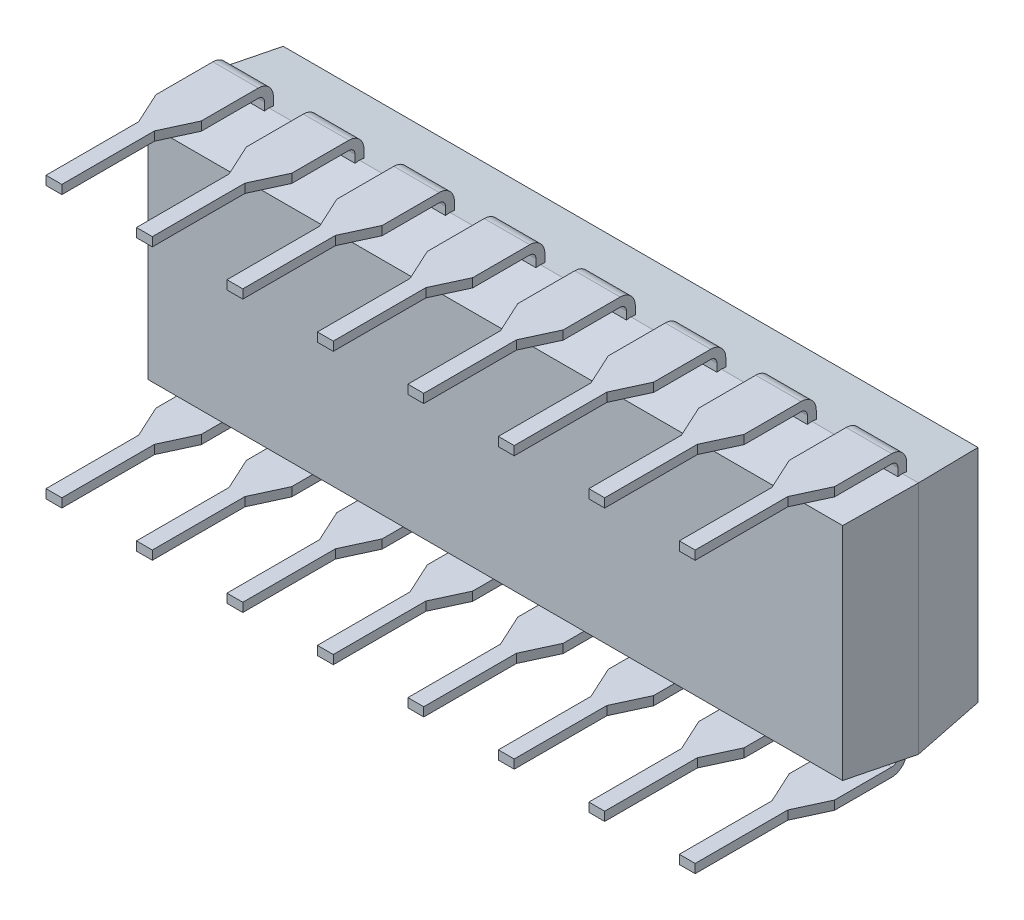
from build123d import *

# Parameters (mm, degrees)
RESSALTO_EXTRUS_O1_DEPTH        = 9.98
CORTE_EXTRUS_O2_DEPTH           = 3.55
ESBO_O8_R                       = 1
CORTE_EXTRUS_O5_DEPTH           = 0.5
ESBO_O6_W                       = 1.275
ESBO_O6_H                       = 0.25
RESSALTO_EXTRUS_O2_DEPTH        = 0.025
ESBO_O7_W                       = 1.275
ESBO_O7_H                       = 0.25
CORTE_EXTRUS_O6_DEPTH           = 0.25
ESBO_O10_W                      = 0.445
ESBO_O10_H                      = 0.25
RESSALTO_EXTRUS_O3_DEPTH        = 2.6
PADR_O_LINEAR1_COUNT            = 8
PADR_O_LINEAR1_PITCH            = 2.54
PADR_O_LINEAR1_COPY_1_SKETCH_W  = 1.275
PADR_O_LINEAR1_COPY_1_SKETCH_H  = 0.25
PADR_O_LINEAR1_COPY_1_DEPTH     = 0.025
PADR_O_LINEAR1_COPY_2_SKETCH_W  = 1.275
PADR_O_LINEAR1_COPY_2_SKETCH_H  = 0.25
PADR_O_LINEAR1_COPY_2_DEPTH     = 0.025
PADR_O_LINEAR1_COPY_3_SKETCH_W  = 1.275
PADR_O_LINEAR1_COPY_3_SKETCH_H  = 0.25
PADR_O_LINEAR1_COPY_3_DEPTH     = 0.025
PADR_O_LINEAR1_COPY_4_SKETCH_W  = 1.275
PADR_O_LINEAR1_COPY_4_SKETCH_H  = 0.25
PADR_O_LINEAR1_COPY_4_DEPTH     = 0.025
PADR_O_LINEAR1_COPY_5_SKETCH_W  = 1.275
PADR_O_LINEAR1_COPY_5_SKETCH_H  = 0.25
PADR_O_LINEAR1_COPY_5_DEPTH     = 0.025
PADR_O_LINEAR1_COPY_6_SKETCH_W  = 1.275
PADR_O_LINEAR1_COPY_6_SKETCH_H  = 0.25
PADR_O_LINEAR1_COPY_6_DEPTH     = 0.025
PADR_O_LINEAR1_COPY_7_SKETCH_W  = 1.275
PADR_O_LINEAR1_COPY_7_SKETCH_H  = 0.25
PADR_O_LINEAR1_COPY_7_DEPTH     = 0.025
PADR_O_LINEAR1_COPY_8_SKETCH_W  = 1.275
PADR_O_LINEAR1_COPY_8_SKETCH_H  = 0.25
PADR_O_LINEAR1_COPY_9_SKETCH_W  = 1.275
PADR_O_LINEAR1_COPY_9_SKETCH_H  = 0.25
PADR_O_LINEAR1_COPY_10_SKETCH_W = 1.275
PADR_O_LINEAR1_COPY_10_SKETCH_H = 0.25
PADR_O_LINEAR1_COPY_11_SKETCH_W = 1.275
PADR_O_LINEAR1_COPY_11_SKETCH_H = 0.25
PADR_O_LINEAR1_COPY_12_SKETCH_W = 1.275
PADR_O_LINEAR1_COPY_12_SKETCH_H = 0.25
PADR_O_LINEAR1_COPY_13_SKETCH_W = 1.275
PADR_O_LINEAR1_COPY_13_SKETCH_H = 0.25
PADR_O_LINEAR1_COPY_14_SKETCH_W = 1.275
PADR_O_LINEAR1_COPY_14_SKETCH_H = 0.25
PADR_O_LINEAR1_COPY_15_DEPTH    = 0.25
PADR_O_LINEAR1_COPY_16_DEPTH    = 0.25
PADR_O_LINEAR1_COPY_17_DEPTH    = 0.25
PADR_O_LINEAR1_COPY_18_DEPTH    = 0.25
PADR_O_LINEAR1_COPY_19_DEPTH    = 0.25
PADR_O_LINEAR1_COPY_20_DEPTH    = 0.25
PADR_O_LINEAR1_COPY_21_DEPTH    = 0.25
PADR_O_LINEAR1_COPY_22_SKETCH_W = 0.445
PADR_O_LINEAR1_COPY_22_SKETCH_H = 0.25
PADR_O_LINEAR1_COPY_22_DEPTH    = 2.6
PADR_O_LINEAR1_COPY_23_SKETCH_W = 0.445
PADR_O_LINEAR1_COPY_23_SKETCH_H = 0.25
PADR_O_LINEAR1_COPY_23_DEPTH    = 2.6
PADR_O_LINEAR1_COPY_24_SKETCH_W = 0.445
PADR_O_LINEAR1_COPY_24_SKETCH_H = 0.25
PADR_O_LINEAR1_COPY_24_DEPTH    = 2.6
PADR_O_LINEAR1_COPY_25_SKETCH_W = 0.445
PADR_O_LINEAR1_COPY_25_SKETCH_H = 0.25
PADR_O_LINEAR1_COPY_25_DEPTH    = 2.6
PADR_O_LINEAR1_COPY_26_SKETCH_W = 0.445
PADR_O_LINEAR1_COPY_26_SKETCH_H = 0.25
PADR_O_LINEAR1_COPY_26_DEPTH    = 2.6
PADR_O_LINEAR1_COPY_27_SKETCH_W = 0.445
PADR_O_LINEAR1_COPY_27_SKETCH_H = 0.25
PADR_O_LINEAR1_COPY_27_DEPTH    = 2.6
PADR_O_LINEAR1_COPY_28_SKETCH_W = 0.445
PADR_O_LINEAR1_COPY_28_SKETCH_H = 0.25
PADR_O_LINEAR1_COPY_28_DEPTH    = 2.6


with BuildPart() as part:
    # Esboço1 → Ressalto-extrusão1 (new body, symmetric)
    with BuildSketch(Plane(origin=(0, 0, 0), x_dir=(0, 0, -1), z_dir=(1, 0, 0))):
        Polygon((0.9, 3.1), (0.9, -3.1), (2.8, -3.3), (4.7, -3.1), (4.7, 3.1), (2.8, 3.3), align=None)
    extrude(amount=RESSALTO_EXTRUS_O1_DEPTH, both=True)

    # Esboço3 → Corte-extrusão2 (cut, symmetric)
    with BuildSketch(Plane(origin=(0, 0, 0), x_dir=(1, 0, 0), z_dir=(0, 1, 0))):
        Polygon((-9.98, 2.8), (-9.749897634, 4.726835982), (-10.916348907, 4.726835982), (-10.916348907, 0.873164018), (-9.749897634, 0.873164018), align=None)
    corte_extrus_o2 = extrude(amount=CORTE_EXTRUS_O2_DEPTH, both=True, mode=Mode.SUBTRACT)

    # Espelhar1: Corte-extrusão2 across plane
    add(corte_extrus_o2.mirror(Plane(origin=(0, 0, 0), x_dir=(0, 0, 1), z_dir=(1, 0, 0))), mode=Mode.SUBTRACT)

    # Esboço8 → Corte-extrusão5 (cut)
    with BuildSketch(Plane(origin=(0, 0, -4.7), x_dir=(-1, 0, 0), z_dir=(0, 0, -1))):
        with Locations((9.753102382, 0)):
            Circle(ESBO_O8_R)
    extrude(amount=-CORTE_EXTRUS_O5_DEPTH, mode=Mode.SUBTRACT)

    # Esboço6 → Ressalto-extrusão2 (add, symmetric)
    with BuildSketch(Plane(origin=(0, 3.3, 0), x_dir=(1, 0, 0), z_dir=(0, 1, 0))):
        with Locations((-8.89, 2.8)):
            Rectangle(ESBO_O6_W, ESBO_O6_H)
    ressalto_extrus_o2 = extrude(amount=RESSALTO_EXTRUS_O2_DEPTH, both=True)

    # Varredura1: sweep along a curve in space
    with BuildLine() as varredura1_path:
        Line((-8.89, 3.325, -2.8), (-8.89, 3.51, -2.8))
        ThreePointArc((-8.89, 3.51, -2.8), (-8.89, 3.722132034, -2.712132034), (-8.89, 3.81, -2.5))
        Line((-8.89, 3.81, -2.5), (-8.89, 3.81, 0))
    # Esboço7 → Varredura1 (sweep)
    with BuildSketch(Plane(origin=(0, 3.325, 0), x_dir=(1, 0, 0), z_dir=(0, 1, 0))):
        with Locations((-8.89, 2.8)):
            Rectangle(ESBO_O7_W, ESBO_O7_H)
    varredura1 = sweep(path=varredura1_path.line)

    # Esboço9 → Corte-extrusão6 (cut)
    with BuildSketch(Plane(origin=(0, 3.935, 0), x_dir=(1, 0, 0), z_dir=(0, 1, 0))):
        Polygon((-9.1125, 0), (-9.5275, 0.9), (-9.5275, -0.2), (-8.2525, -0.2), (-8.2525, 0.9), (-8.6675, 0), align=None)
    corte_extrus_o6 = extrude(amount=-CORTE_EXTRUS_O6_DEPTH, mode=Mode.SUBTRACT)

    # Esboço10 → Ressalto-extrusão3 (add)
    with BuildSketch(Plane.XY):
        with Locations((-8.89, 3.81)):
            Rectangle(ESBO_O10_W, ESBO_O10_H)
    ressalto_extrus_o3 = extrude(amount=RESSALTO_EXTRUS_O3_DEPTH)

    # Espelhar2: Ressalto-extrusão2, Varredura1, Corte-extrusão6, Ressalto-extrusão3 across plane
    add(ressalto_extrus_o2.mirror(Plane.ZX))
    add(varredura1.mirror(Plane.ZX))
    add(corte_extrus_o6.mirror(Plane.ZX), mode=Mode.SUBTRACT)
    add(ressalto_extrus_o3.mirror(Plane.ZX))

    # Padrão linear1: Ressalto-extrusão2, Varredura1, Corte-extrusão6, Ressalto-extrusão3 ×8
    with Locations(*[(i * PADR_O_LINEAR1_PITCH, 0, 0) for i in range(1, PADR_O_LINEAR1_COUNT)]):
        add(ressalto_extrus_o2)
        add(varredura1)
        add(corte_extrus_o6, mode=Mode.SUBTRACT)
        add(ressalto_extrus_o3)

    # Padrão linear1 copy 1 sketch → Padrão linear1 copy 1 (add, symmetric)
    with BuildSketch(Plane(origin=(2.54, -3.3, 0), x_dir=(1, 0, 0), z_dir=(0, -1, 0))):
        with Locations((-8.89, -2.8)):
            Rectangle(PADR_O_LINEAR1_COPY_1_SKETCH_W, PADR_O_LINEAR1_COPY_1_SKETCH_H)
    extrude(amount=PADR_O_LINEAR1_COPY_1_DEPTH, both=True)

    # Padrão linear1 copy 2 sketch → Padrão linear1 copy 2 (add, symmetric)
    with BuildSketch(Plane(origin=(5.08, -3.3, 0), x_dir=(1, 0, 0), z_dir=(0, -1, 0))):
        with Locations((-8.89, -2.8)):
            Rectangle(PADR_O_LINEAR1_COPY_2_SKETCH_W, PADR_O_LINEAR1_COPY_2_SKETCH_H)
    extrude(amount=PADR_O_LINEAR1_COPY_2_DEPTH, both=True)

    # Padrão linear1 copy 3 sketch → Padrão linear1 copy 3 (add, symmetric)
    with BuildSketch(Plane(origin=(7.62, -3.3, 0), x_dir=(1, 0, 0), z_dir=(0, -1, 0))):
        with Locations((-8.89, -2.8)):
            Rectangle(PADR_O_LINEAR1_COPY_3_SKETCH_W, PADR_O_LINEAR1_COPY_3_SKETCH_H)
    extrude(amount=PADR_O_LINEAR1_COPY_3_DEPTH, both=True)

    # Padrão linear1 copy 4 sketch → Padrão linear1 copy 4 (add, symmetric)
    with BuildSketch(Plane(origin=(10.16, -3.3, 0), x_dir=(1, 0, 0), z_dir=(0, -1, 0))):
        with Locations((-8.89, -2.8)):
            Rectangle(PADR_O_LINEAR1_COPY_4_SKETCH_W, PADR_O_LINEAR1_COPY_4_SKETCH_H)
    extrude(amount=PADR_O_LINEAR1_COPY_4_DEPTH, both=True)

    # Padrão linear1 copy 5 sketch → Padrão linear1 copy 5 (add, symmetric)
    with BuildSketch(Plane(origin=(12.7, -3.3, 0), x_dir=(1, 0, 0), z_dir=(0, -1, 0))):
        with Locations((-8.89, -2.8)):
            Rectangle(PADR_O_LINEAR1_COPY_5_SKETCH_W, PADR_O_LINEAR1_COPY_5_SKETCH_H)
    extrude(amount=PADR_O_LINEAR1_COPY_5_DEPTH, both=True)

    # Padrão linear1 copy 6 sketch → Padrão linear1 copy 6 (add, symmetric)
    with BuildSketch(Plane(origin=(15.24, -3.3, 0), x_dir=(1, 0, 0), z_dir=(0, -1, 0))):
        with Locations((-8.89, -2.8)):
            Rectangle(PADR_O_LINEAR1_COPY_6_SKETCH_W, PADR_O_LINEAR1_COPY_6_SKETCH_H)
    extrude(amount=PADR_O_LINEAR1_COPY_6_DEPTH, both=True)

    # Padrão linear1 copy 7 sketch → Padrão linear1 copy 7 (add, symmetric)
    with BuildSketch(Plane(origin=(17.78, -3.3, 0), x_dir=(1, 0, 0), z_dir=(0, -1, 0))):
        with Locations((-8.89, -2.8)):
            Rectangle(PADR_O_LINEAR1_COPY_7_SKETCH_W, PADR_O_LINEAR1_COPY_7_SKETCH_H)
    extrude(amount=PADR_O_LINEAR1_COPY_7_DEPTH, both=True)

    # Padrão linear1 copy 8: sweep along a curve in space
    with BuildLine() as padr_o_linear1_copy_8_path:
        Line((-6.35, -3.325, -2.8), (-6.35, -3.51, -2.8))
        ThreePointArc((-6.35, -3.51, -2.8), (-6.35, -3.722132034, -2.712132034), (-6.35, -3.81, -2.5))
        Line((-6.35, -3.81, -2.5), (-6.35, -3.81, 0))
    # Padrão linear1 copy 8 sketch → Padrão linear1 copy 8 (sweep)
    with BuildSketch(Plane(origin=(2.54, -3.325, 0), x_dir=(1, 0, 0), z_dir=(0, -1, 0))):
        with Locations((-8.89, -2.8)):
            Rectangle(PADR_O_LINEAR1_COPY_8_SKETCH_W, PADR_O_LINEAR1_COPY_8_SKETCH_H)
    sweep(path=padr_o_linear1_copy_8_path.line)

    # Padrão linear1 copy 9: sweep along a curve in space
    with BuildLine() as padr_o_linear1_copy_9_path:
        Line((-3.81, -3.325, -2.8), (-3.81, -3.51, -2.8))
        ThreePointArc((-3.81, -3.51, -2.8), (-3.81, -3.722132034, -2.712132034), (-3.81, -3.81, -2.5))
        Line((-3.81, -3.81, -2.5), (-3.81, -3.81, 0))
    # Padrão linear1 copy 9 sketch → Padrão linear1 copy 9 (sweep)
    with BuildSketch(Plane(origin=(5.08, -3.325, 0), x_dir=(1, 0, 0), z_dir=(0, -1, 0))):
        with Locations((-8.89, -2.8)):
            Rectangle(PADR_O_LINEAR1_COPY_9_SKETCH_W, PADR_O_LINEAR1_COPY_9_SKETCH_H)
    sweep(path=padr_o_linear1_copy_9_path.line)

    # Padrão linear1 copy 10: sweep along a curve in space
    with BuildLine() as padr_o_linear1_copy_10_path:
        Line((-1.27, -3.325, -2.8), (-1.27, -3.51, -2.8))
        ThreePointArc((-1.27, -3.51, -2.8), (-1.27, -3.722132034, -2.712132034), (-1.27, -3.81, -2.5))
        Line((-1.27, -3.81, -2.5), (-1.27, -3.81, 0))
    # Padrão linear1 copy 10 sketch → Padrão linear1 copy 10 (sweep)
    with BuildSketch(Plane(origin=(7.62, -3.325, 0), x_dir=(1, 0, 0), z_dir=(0, -1, 0))):
        with Locations((-8.89, -2.8)):
            Rectangle(PADR_O_LINEAR1_COPY_10_SKETCH_W, PADR_O_LINEAR1_COPY_10_SKETCH_H)
    sweep(path=padr_o_linear1_copy_10_path.line)

    # Padrão linear1 copy 11: sweep along a curve in space
    with BuildLine() as padr_o_linear1_copy_11_path:
        Line((1.27, -3.325, -2.8), (1.27, -3.51, -2.8))
        ThreePointArc((1.27, -3.51, -2.8), (1.27, -3.722132034, -2.712132034), (1.27, -3.81, -2.5))
        Line((1.27, -3.81, -2.5), (1.27, -3.81, 0))
    # Padrão linear1 copy 11 sketch → Padrão linear1 copy 11 (sweep)
    with BuildSketch(Plane(origin=(10.16, -3.325, 0), x_dir=(1, 0, 0), z_dir=(0, -1, 0))):
        with Locations((-8.89, -2.8)):
            Rectangle(PADR_O_LINEAR1_COPY_11_SKETCH_W, PADR_O_LINEAR1_COPY_11_SKETCH_H)
    sweep(path=padr_o_linear1_copy_11_path.line)

    # Padrão linear1 copy 12: sweep along a curve in space
    with BuildLine() as padr_o_linear1_copy_12_path:
        Line((3.81, -3.325, -2.8), (3.81, -3.51, -2.8))
        ThreePointArc((3.81, -3.51, -2.8), (3.81, -3.722132034, -2.712132034), (3.81, -3.81, -2.5))
        Line((3.81, -3.81, -2.5), (3.81, -3.81, 0))
    # Padrão linear1 copy 12 sketch → Padrão linear1 copy 12 (sweep)
    with BuildSketch(Plane(origin=(12.7, -3.325, 0), x_dir=(1, 0, 0), z_dir=(0, -1, 0))):
        with Locations((-8.89, -2.8)):
            Rectangle(PADR_O_LINEAR1_COPY_12_SKETCH_W, PADR_O_LINEAR1_COPY_12_SKETCH_H)
    sweep(path=padr_o_linear1_copy_12_path.line)

    # Padrão linear1 copy 13: sweep along a curve in space
    with BuildLine() as padr_o_linear1_copy_13_path:
        Line((6.35, -3.325, -2.8), (6.35, -3.51, -2.8))
        ThreePointArc((6.35, -3.51, -2.8), (6.35, -3.722132034, -2.712132034), (6.35, -3.81, -2.5))
        Line((6.35, -3.81, -2.5), (6.35, -3.81, 0))
    # Padrão linear1 copy 13 sketch → Padrão linear1 copy 13 (sweep)
    with BuildSketch(Plane(origin=(15.24, -3.325, 0), x_dir=(1, 0, 0), z_dir=(0, -1, 0))):
        with Locations((-8.89, -2.8)):
            Rectangle(PADR_O_LINEAR1_COPY_13_SKETCH_W, PADR_O_LINEAR1_COPY_13_SKETCH_H)
    sweep(path=padr_o_linear1_copy_13_path.line)

    # Padrão linear1 copy 14: sweep along a curve in space
    with BuildLine() as padr_o_linear1_copy_14_path:
        Line((8.89, -3.325, -2.8), (8.89, -3.51, -2.8))
        ThreePointArc((8.89, -3.51, -2.8), (8.89, -3.722132034, -2.712132034), (8.89, -3.81, -2.5))
        Line((8.89, -3.81, -2.5), (8.89, -3.81, 0))
    # Padrão linear1 copy 14 sketch → Padrão linear1 copy 14 (sweep)
    with BuildSketch(Plane(origin=(17.78, -3.325, 0), x_dir=(1, 0, 0), z_dir=(0, -1, 0))):
        with Locations((-8.89, -2.8)):
            Rectangle(PADR_O_LINEAR1_COPY_14_SKETCH_W, PADR_O_LINEAR1_COPY_14_SKETCH_H)
    sweep(path=padr_o_linear1_copy_14_path.line)

    # Padrão linear1 copy 15 sketch → Padrão linear1 copy 15 (cut)
    with BuildSketch(Plane(origin=(2.54, -3.935, 0), x_dir=(1, 0, 0), z_dir=(0, -1, 0))):
        Polygon((-9.1125, 0), (-9.5275, -0.9), (-9.5275, 0.2), (-8.2525, 0.2), (-8.2525, -0.9), (-8.6675, 0), align=None)
    extrude(amount=-PADR_O_LINEAR1_COPY_15_DEPTH, mode=Mode.SUBTRACT)

    # Padrão linear1 copy 16 sketch → Padrão linear1 copy 16 (cut)
    with BuildSketch(Plane(origin=(5.08, -3.935, 0), x_dir=(1, 0, 0), z_dir=(0, -1, 0))):
        Polygon((-9.1125, 0), (-9.5275, -0.9), (-9.5275, 0.2), (-8.2525, 0.2), (-8.2525, -0.9), (-8.6675, 0), align=None)
    extrude(amount=-PADR_O_LINEAR1_COPY_16_DEPTH, mode=Mode.SUBTRACT)

    # Padrão linear1 copy 17 sketch → Padrão linear1 copy 17 (cut)
    with BuildSketch(Plane(origin=(7.62, -3.935, 0), x_dir=(1, 0, 0), z_dir=(0, -1, 0))):
        Polygon((-9.1125, 0), (-9.5275, -0.9), (-9.5275, 0.2), (-8.2525, 0.2), (-8.2525, -0.9), (-8.6675, 0), align=None)
    extrude(amount=-PADR_O_LINEAR1_COPY_17_DEPTH, mode=Mode.SUBTRACT)

    # Padrão linear1 copy 18 sketch → Padrão linear1 copy 18 (cut)
    with BuildSketch(Plane(origin=(10.16, -3.935, 0), x_dir=(1, 0, 0), z_dir=(0, -1, 0))):
        Polygon((-9.1125, 0), (-9.5275, -0.9), (-9.5275, 0.2), (-8.2525, 0.2), (-8.2525, -0.9), (-8.6675, 0), align=None)
    extrude(amount=-PADR_O_LINEAR1_COPY_18_DEPTH, mode=Mode.SUBTRACT)

    # Padrão linear1 copy 19 sketch → Padrão linear1 copy 19 (cut)
    with BuildSketch(Plane(origin=(12.7, -3.935, 0), x_dir=(1, 0, 0), z_dir=(0, -1, 0))):
        Polygon((-9.1125, 0), (-9.5275, -0.9), (-9.5275, 0.2), (-8.2525, 0.2), (-8.2525, -0.9), (-8.6675, 0), align=None)
    extrude(amount=-PADR_O_LINEAR1_COPY_19_DEPTH, mode=Mode.SUBTRACT)

    # Padrão linear1 copy 20 sketch → Padrão linear1 copy 20 (cut)
    with BuildSketch(Plane(origin=(15.24, -3.935, 0), x_dir=(1, 0, 0), z_dir=(0, -1, 0))):
        Polygon((-9.1125, 0), (-9.5275, -0.9), (-9.5275, 0.2), (-8.2525, 0.2), (-8.2525, -0.9), (-8.6675, 0), align=None)
    extrude(amount=-PADR_O_LINEAR1_COPY_20_DEPTH, mode=Mode.SUBTRACT)

    # Padrão linear1 copy 21 sketch → Padrão linear1 copy 21 (cut)
    with BuildSketch(Plane(origin=(17.78, -3.935, 0), x_dir=(1, 0, 0), z_dir=(0, -1, 0))):
        Polygon((-9.1125, 0), (-9.5275, -0.9), (-9.5275, 0.2), (-8.2525, 0.2), (-8.2525, -0.9), (-8.6675, 0), align=None)
    extrude(amount=-PADR_O_LINEAR1_COPY_21_DEPTH, mode=Mode.SUBTRACT)

    # Padrão linear1 copy 22 sketch → Padrão linear1 copy 22 (add)
    with BuildSketch(Plane(origin=(2.54, 0, 0), x_dir=(1, 0, 0), z_dir=(0, 0, 1))):
        with Locations((-8.89, -3.81)):
            Rectangle(PADR_O_LINEAR1_COPY_22_SKETCH_W, PADR_O_LINEAR1_COPY_22_SKETCH_H)
    extrude(amount=PADR_O_LINEAR1_COPY_22_DEPTH)

    # Padrão linear1 copy 23 sketch → Padrão linear1 copy 23 (add)
    with BuildSketch(Plane(origin=(5.08, 0, 0), x_dir=(1, 0, 0), z_dir=(0, 0, 1))):
        with Locations((-8.89, -3.81)):
            Rectangle(PADR_O_LINEAR1_COPY_23_SKETCH_W, PADR_O_LINEAR1_COPY_23_SKETCH_H)
    extrude(amount=PADR_O_LINEAR1_COPY_23_DEPTH)

    # Padrão linear1 copy 24 sketch → Padrão linear1 copy 24 (add)
    with BuildSketch(Plane(origin=(7.62, 0, 0), x_dir=(1, 0, 0), z_dir=(0, 0, 1))):
        with Locations((-8.89, -3.81)):
            Rectangle(PADR_O_LINEAR1_COPY_24_SKETCH_W, PADR_O_LINEAR1_COPY_24_SKETCH_H)
    extrude(amount=PADR_O_LINEAR1_COPY_24_DEPTH)

    # Padrão linear1 copy 25 sketch → Padrão linear1 copy 25 (add)
    with BuildSketch(Plane(origin=(10.16, 0, 0), x_dir=(1, 0, 0), z_dir=(0, 0, 1))):
        with Locations((-8.89, -3.81)):
            Rectangle(PADR_O_LINEAR1_COPY_25_SKETCH_W, PADR_O_LINEAR1_COPY_25_SKETCH_H)
    extrude(amount=PADR_O_LINEAR1_COPY_25_DEPTH)

    # Padrão linear1 copy 26 sketch → Padrão linear1 copy 26 (add)
    with BuildSketch(Plane(origin=(12.7, 0, 0), x_dir=(1, 0, 0), z_dir=(0, 0, 1))):
        with Locations((-8.89, -3.81)):
            Rectangle(PADR_O_LINEAR1_COPY_26_SKETCH_W, PADR_O_LINEAR1_COPY_26_SKETCH_H)
    extrude(amount=PADR_O_LINEAR1_COPY_26_DEPTH)

    # Padrão linear1 copy 27 sketch → Padrão linear1 copy 27 (add)
    with BuildSketch(Plane(origin=(15.24, 0, 0), x_dir=(1, 0, 0), z_dir=(0, 0, 1))):
        with Locations((-8.89, -3.81)):
            Rectangle(PADR_O_LINEAR1_COPY_27_SKETCH_W, PADR_O_LINEAR1_COPY_27_SKETCH_H)
    extrude(amount=PADR_O_LINEAR1_COPY_27_DEPTH)

    # Padrão linear1 copy 28 sketch → Padrão linear1 copy 28 (add)
    with BuildSketch(Plane(origin=(17.78, 0, 0), x_dir=(1, 0, 0), z_dir=(0, 0, 1))):
        with Locations((-8.89, -3.81)):
            Rectangle(PADR_O_LINEAR1_COPY_28_SKETCH_W, PADR_O_LINEAR1_COPY_28_SKETCH_H)
    extrude(amount=PADR_O_LINEAR1_COPY_28_DEPTH)


solid = part.part
